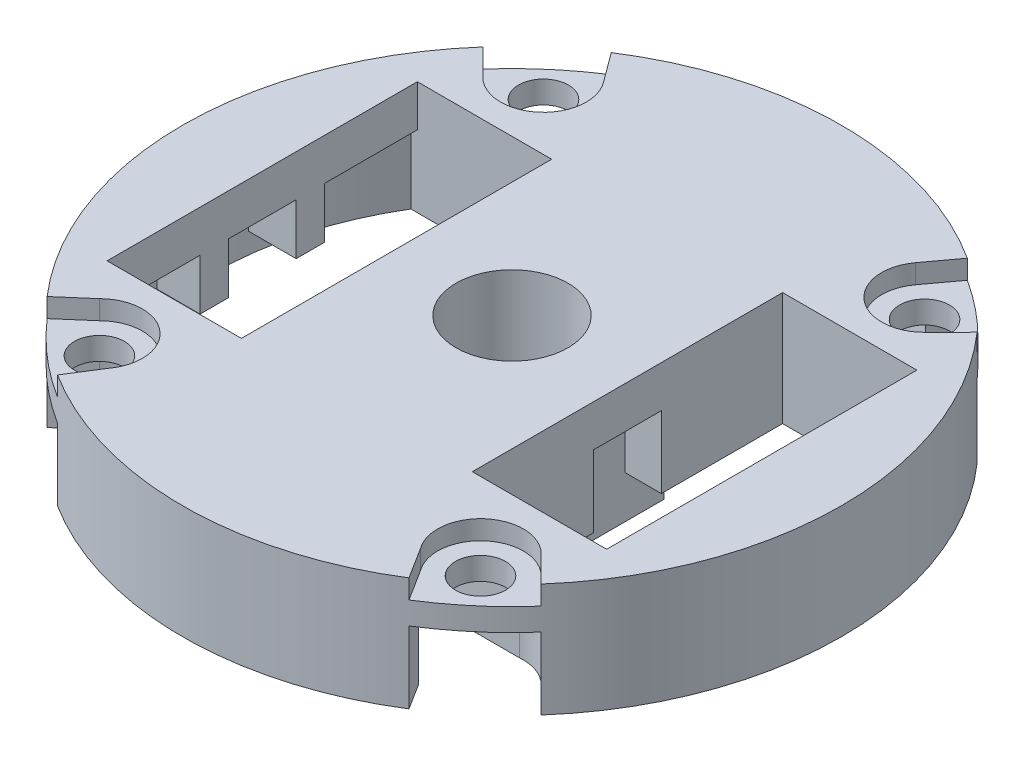
from build123d import *
from build123d.topology import SkipClean

# Parameters (mm, degrees)
SKETCH1_W           = 6.45
SKETCH1_H           = 14.9
SKETCH1_R           = 2.69
BOSS_EXTRUDE1_DEPTH = 2
SKETCH1_4_R         = 1.2
BOSS_EXTRUDE2_DEPTH = 1.08
SKETCH2_R           = 2.69
BOSS_EXTRUDE3_DEPTH = 3.45
BOSS_EXTRUDE4_START = -3.45
BOSS_EXTRUDE4_DEPTH = 3.45
BOSS_EXTRUDE5_START = -2.45
BOSS_EXTRUDE5_DEPTH = 2.45
BOSS_EXTRUDE6_START = -3.45
SKETCH2_5_R         = 2.69
BOSS_EXTRUDE6_DEPTH = 3.45
BOSS_EXTRUDE7_START = -5.5
SKETCH2_6_W         = 7.59
SKETCH2_6_H         = 7
SKETCH2_6_R         = 2.69
BOSS_EXTRUDE7_DEPTH = 5.5


with BuildPart() as part:
    # Sketch1 → Boss-Extrude1 (new body)
    with BuildSketch(Plane(origin=(0, 0, 0), x_dir=(1, 0, 0), z_dir=(0, 1, 0))):
        with BuildLine():
            ThreePointArc((-7.492590556, 11.885435909), (-7.808434164, 9.098816182), (-10.610710111, 9.209523926))
            Line((-10.610710111, 9.209523926), (-11.865304556, 10.471159095))
            ThreePointArc((-11.865304556, 10.471159095), (-15.824865609, 0.065218614), (-11.951209075, -10.373004706))
            Line((-11.951209075, -10.373004706), (-10.610710111, -9.209523926))
            ThreePointArc((-10.610710111, -9.209523926), (-7.808434164, -9.098816182), (-7.492590556, -11.885435909))
            Line((-7.492590556, -11.885435909), (-8.439163385, -13.386976745))
            ThreePointArc((-8.439163385, -13.386976745), (0, -15.825), (8.439163385, -13.386976745))
            Line((8.439163385, -13.386976745), (7.492590556, -11.885435909))
            ThreePointArc((7.492590556, -11.885435909), (7.808434164, -9.098816182), (10.610710111, -9.209523926))
            Line((10.610710111, -9.209523926), (11.865304556, -10.471159095))
            ThreePointArc((11.865304556, -10.471159095), (14.802011174, -5.597418173), (15.825, 0))
            ThreePointArc((15.825, 0), (14.802011174, 5.597418173), (11.865304556, 10.471159095))
            Line((11.865304556, 10.471159095), (10.610710111, 9.209523926))
            ThreePointArc((10.610710111, 9.209523926), (7.808434164, 9.098816182), (7.492590556, 11.885435909))
            Line((7.492590556, 11.885435909), (8.549217648, 13.316962965))
            ThreePointArc((8.549217648, 13.316962965), (0, 15.825), (-8.549217648, 13.316962965))
            Line((-8.549217648, 13.316962965), (-7.492590556, 11.885435909))
        make_face()
        with Locations((-8.77, 0)):
            Rectangle(SKETCH1_W, SKETCH1_H, mode=Mode.SUBTRACT)
        Circle(SKETCH1_R, mode=Mode.SUBTRACT)
        with Locations((8.77, 0)):
            Rectangle(SKETCH1_W, SKETCH1_H, mode=Mode.SUBTRACT)
    extrude(amount=BOSS_EXTRUDE1_DEPTH)

    # Sketch1_4 → Boss-Extrude2 (add)
    # profile 1 of 4: a face of its own
    with BuildSketch(Plane(origin=(0, 0, 0), x_dir=(1, 0, 0), z_dir=(0, 1, 0))):
        with BuildLine():
            Line((-11.865304556, 10.471159095), (-10.610710111, 9.209523926))
            ThreePointArc((-10.610710111, 9.209523926), (-7.808434164, 9.098816182), (-7.492590556, 11.885435909))
            Line((-7.492590556, 11.885435909), (-8.549217648, 13.316962965))
            ThreePointArc((-8.549217648, 13.316962965), (-10.305960854, 12.009071399), (-11.865304556, 10.471159095))
        make_face()
        with Locations((-9.15, 10.662082348)):
            Circle(SKETCH1_4_R, mode=Mode.SUBTRACT)
    # profile 2 of 4: a face of its own
    with BuildSketch(Plane(origin=(0, 0, 0), x_dir=(1, 0, 0), z_dir=(0, 1, 0))):
        with BuildLine():
            Line((-10.610710111, -9.209523926), (-11.951209075, -10.373004706))
            ThreePointArc((-11.951209075, -10.373004706), (-10.305960854, -12.009071399), (-8.439163385, -13.386976745))
            Line((-8.439163385, -13.386976745), (-7.492590556, -11.885435909))
            ThreePointArc((-7.492590556, -11.885435909), (-7.808434164, -9.098816182), (-10.610710111, -9.209523926))
        make_face()
        with Locations((-9.15, -10.662082348)):
            Circle(SKETCH1_4_R, mode=Mode.SUBTRACT)
    # profile 3 of 4: a face of its own
    with BuildSketch(Plane(origin=(0, 0, 0), x_dir=(1, 0, 0), z_dir=(0, 1, 0))):
        with BuildLine():
            ThreePointArc((11.865304556, 10.471159095), (10.305960854, 12.009071399), (8.549217648, 13.316962965))
            Line((8.549217648, 13.316962965), (7.492590556, 11.885435909))
            ThreePointArc((7.492590556, 11.885435909), (7.808434164, 9.098816182), (10.610710111, 9.209523926))
            Line((10.610710111, 9.209523926), (11.865304556, 10.471159095))
        make_face()
        with Locations((9.15, 10.662082348)):
            Circle(SKETCH1_4_R, mode=Mode.SUBTRACT)
    # profile 4 of 4: a face of its own
    with BuildSketch(Plane(origin=(0, 0, 0), x_dir=(1, 0, 0), z_dir=(0, 1, 0))):
        with BuildLine():
            Line((7.492590556, -11.885435909), (8.439163385, -13.386976745))
            ThreePointArc((8.439163385, -13.386976745), (10.256381074, -12.051442746), (11.865304556, -10.471159095))
            Line((11.865304556, -10.471159095), (10.610710111, -9.209523926))
            ThreePointArc((10.610710111, -9.209523926), (7.808434164, -9.098816182), (7.492590556, -11.885435909))
        make_face()
        with Locations((9.15, -10.662082348)):
            Circle(SKETCH1_4_R, mode=Mode.SUBTRACT)
    extrude(amount=BOSS_EXTRUDE2_DEPTH)

    # Sketch2_3 → Boss-Extrude4 (add)
    with BuildSketch(Plane(origin=(0, 0, 0), x_dir=(1, 0, 0), z_dir=(0, 1, 0)).offset(BOSS_EXTRUDE4_START)):
        with BuildLine():
            Line((-8.549217648, 13.316962965), (-7.692058181, 12.155676285))
            ThreePointArc((-7.692058181, 12.155676285), (0, 14.385), (7.692058181, 12.155676285))
            Line((7.692058181, 12.155676285), (8.549217648, 13.316962965))
            ThreePointArc((8.549217648, 13.316962965), (0, 15.825), (-8.549217648, 13.316962965))
        make_face()
        with BuildLine():
            ThreePointArc((7.671239513, -12.168825307), (0, -14.385), (-7.671239513, -12.168825307))
            Line((-7.671239513, -12.168825307), (-8.439163385, -13.386976745))
            ThreePointArc((-8.439163385, -13.386976745), (0, -15.825), (8.439163385, -13.386976745))
            Line((8.439163385, -13.386976745), (7.671239513, -12.168825307))
        make_face()
    extrude(amount=BOSS_EXTRUDE4_DEPTH)

    # Sketch2_4 → Boss-Extrude5 (add)
    with BuildSketch(Plane(origin=(0, 0, 0), x_dir=(1, 0, 0), z_dir=(0, 1, 0)).offset(BOSS_EXTRUDE5_START)):
        with BuildLine():
            Line((-11.995, 1.63), (-11.995, 2.98))
            Line((-11.995, 2.98), (-14.072946564, 2.98))
            ThreePointArc((-14.072946564, 2.98), (-14.198702945, 2.307609084), (-14.292351976, 1.63))
            Line((-14.292351976, 1.63), (-11.995, 1.63))
        make_face()
        with BuildLine():
            Line((-11.995, -2.98), (-11.995, -1.63))
            Line((-11.995, -1.63), (-14.292351976, -1.63))
            ThreePointArc((-14.292351976, -1.63), (-14.198702945, -2.307609084), (-14.072946564, -2.98))
            Line((-14.072946564, -2.98), (-11.995, -2.98))
        make_face()
        with BuildLine():
            ThreePointArc((14.292351976, 1.63), (14.198702945, 2.307609084), (14.072946564, 2.98))
            Line((14.072946564, 2.98), (11.995, 2.98))
            Line((11.995, 2.98), (11.995, 1.63))
            Line((11.995, 1.63), (14.292351976, 1.63))
        make_face()
        with BuildLine():
            Line((11.995, -2.98), (14.072946564, -2.98))
            ThreePointArc((14.072946564, -2.98), (14.198702945, -2.307609084), (14.292351976, -1.63))
            Line((14.292351976, -1.63), (11.995, -1.63))
            Line((11.995, -1.63), (11.995, -2.98))
        make_face()
    extrude(amount=BOSS_EXTRUDE5_DEPTH)

    # Sketch2_5 → Boss-Extrude6 (add)
    with BuildSketch(Plane(origin=(0, 0, 0), x_dir=(1, 0, 0), z_dir=(0, 1, 0)).offset(BOSS_EXTRUDE6_START)):
        with BuildLine():
            ThreePointArc((3.5, 0), (2.474873734, 2.474873734), (0, 3.5))
            ThreePointArc((0, 3.5), (-3.5, 0), (0, -3.5))
            ThreePointArc((0, -3.5), (2.474873734, -2.474873734), (3.5, 0))
        make_face()
        Circle(SKETCH2_5_R, mode=Mode.SUBTRACT)
    extrude(amount=BOSS_EXTRUDE6_DEPTH)



with BuildPart() as body_2:
    # Sketch2 → Boss-Extrude3 (new body)
    with BuildSketch(Plane(origin=(0, 0, 0), x_dir=(1, 0, 0), z_dir=(0, 1, 0))):
        with BuildLine():
            Line((-4.385, -3.5), (4.385, -3.5))
            Line((4.385, -3.5), (4.385, -8.61))
            Line((4.385, -8.61), (8.969561545, -8.61))
            ThreePointArc((8.969561545, -8.61), (9.85684589, -8.727148528), (10.610710111, -9.209523926))
            Line((10.610710111, -9.209523926), (11.865304556, -10.471159095))
            ThreePointArc((11.865304556, -10.471159095), (15.825, 0), (11.865304556, 10.471159095))
            Line((11.865304556, 10.471159095), (10.610710111, 9.209523926))
            ThreePointArc((10.610710111, 9.209523926), (9.85684589, 8.727148528), (8.969561545, 8.61))
            Line((8.969561545, 8.61), (4.385, 8.61))
            Line((4.385, 8.61), (4.385, 3.5))
            Line((4.385, 3.5), (-4.385, 3.5))
            Line((-4.385, 3.5), (-4.385, 8.61))
            Line((-4.385, 8.61), (-8.969561545, 8.61))
            ThreePointArc((-8.969561545, 8.61), (-9.85684589, 8.727148528), (-10.610710111, 9.209523926))
            Line((-10.610710111, 9.209523926), (-11.865304556, 10.471159095))
            ThreePointArc((-11.865304556, 10.471159095), (-15.824865609, 0.065218614), (-11.951209075, -10.373004706))
            Line((-11.951209075, -10.373004706), (-10.610710111, -9.209523926))
            ThreePointArc((-10.610710111, -9.209523926), (-9.85684589, -8.727148528), (-8.969561545, -8.61))
            Line((-8.969561545, -8.61), (-4.385, -8.61))
            Line((-4.385, -8.61), (-4.385, -3.5))
        make_face()
        with BuildLine():
            Line((-5.545, 7.45), (-5.545, 1.63))
            Line((-5.545, 1.63), (-3.795, 1.63))
            Line((-3.795, 1.63), (-3.795, -1.63))
            Line((-3.795, -1.63), (-5.545, -1.63))
            Line((-5.545, -1.63), (-5.545, -7.45))
            Line((-5.545, -7.45), (-12.30551604, -7.45))
            ThreePointArc((-12.30551604, -7.45), (-14.385, 0), (-12.30551604, 7.45))
            Line((-12.30551604, 7.45), (-5.545, 7.45))
        make_face(mode=Mode.SUBTRACT)
        Circle(SKETCH2_R, mode=Mode.SUBTRACT)
        with BuildLine():
            Line((3.795, -1.63), (3.795, 1.63))
            Line((3.795, 1.63), (5.545, 1.63))
            Line((5.545, 1.63), (5.545, 7.45))
            Line((5.545, 7.45), (12.30551604, 7.45))
            ThreePointArc((12.30551604, 7.45), (14.385, 0), (12.30551604, -7.45))
            Line((12.30551604, -7.45), (5.545, -7.45))
            Line((5.545, -7.45), (5.545, -1.63))
            Line((5.545, -1.63), (3.795, -1.63))
        make_face(mode=Mode.SUBTRACT)
    extrude(amount=-BOSS_EXTRUDE3_DEPTH)


with BuildPart() as part_1:
    with SkipClean():  # the faces are left unmerged after this step: merging them gives an invalid solid
        add(part.part)

        add(body_2.part)  # Boss-Extrude7 merges body 2
        # Sketch2_6 → Boss-Extrude7 (add)
        with BuildSketch(Plane(origin=(0, 0, 0), x_dir=(1, 0, 0), z_dir=(0, 1, 0)).offset(BOSS_EXTRUDE7_START)):
            Rectangle(SKETCH2_6_W, SKETCH2_6_H)
            Circle(SKETCH2_6_R, mode=Mode.SUBTRACT)
        extrude(amount=BOSS_EXTRUDE7_DEPTH)


solid = part_1.part
